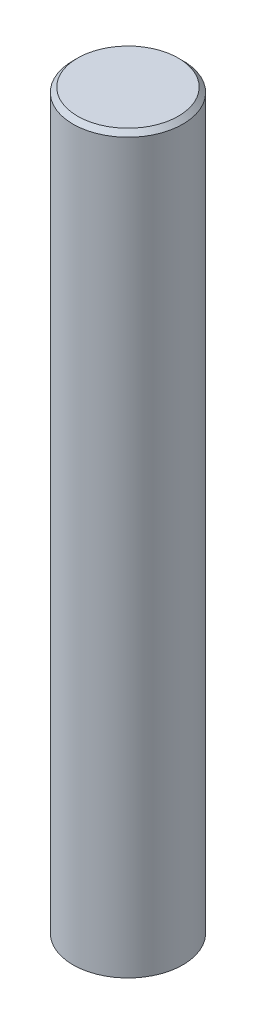
from build123d import *

# Parameters (mm, degrees)
SKETCH1_R           = 12
BOSS_EXTRUDE1_DEPTH = 160
CHAMFER1_SIZE       = 1


with BuildPart() as part:
    # Sketch1 → Boss-Extrude1 (new body)
    with BuildSketch(Plane(origin=(0, 0, 0), x_dir=(1, 0, 0), z_dir=(0, 1, 0))):
        Circle(SKETCH1_R)
    extrude(amount=BOSS_EXTRUDE1_DEPTH)

    # Chamfer1
    chamfer1_edges = [part.edges().sort_by_distance(p)[0] for p in [
        (-12, 160, 0),
    ]]
    chamfer(chamfer1_edges, length=CHAMFER1_SIZE)


solid = part.part
